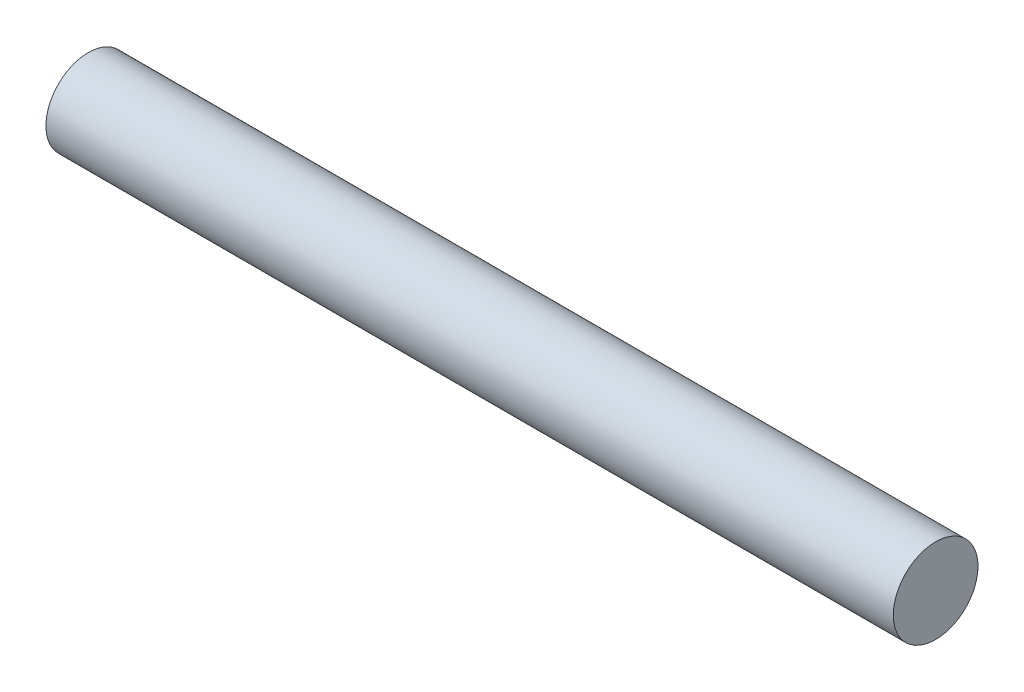
from build123d import *

# Parameters (mm, degrees)
SKETCH1_R  = 3.175
MAIN_DEPTH = 31.75


with BuildPart() as part:
    # Sketch1 → main (new body, symmetric)
    with BuildSketch(Plane(origin=(0, 0, 0), x_dir=(0, 0, -1), z_dir=(1, 0, 0))):
        Circle(SKETCH1_R)
    extrude(amount=MAIN_DEPTH, both=True)


solid = part.part
